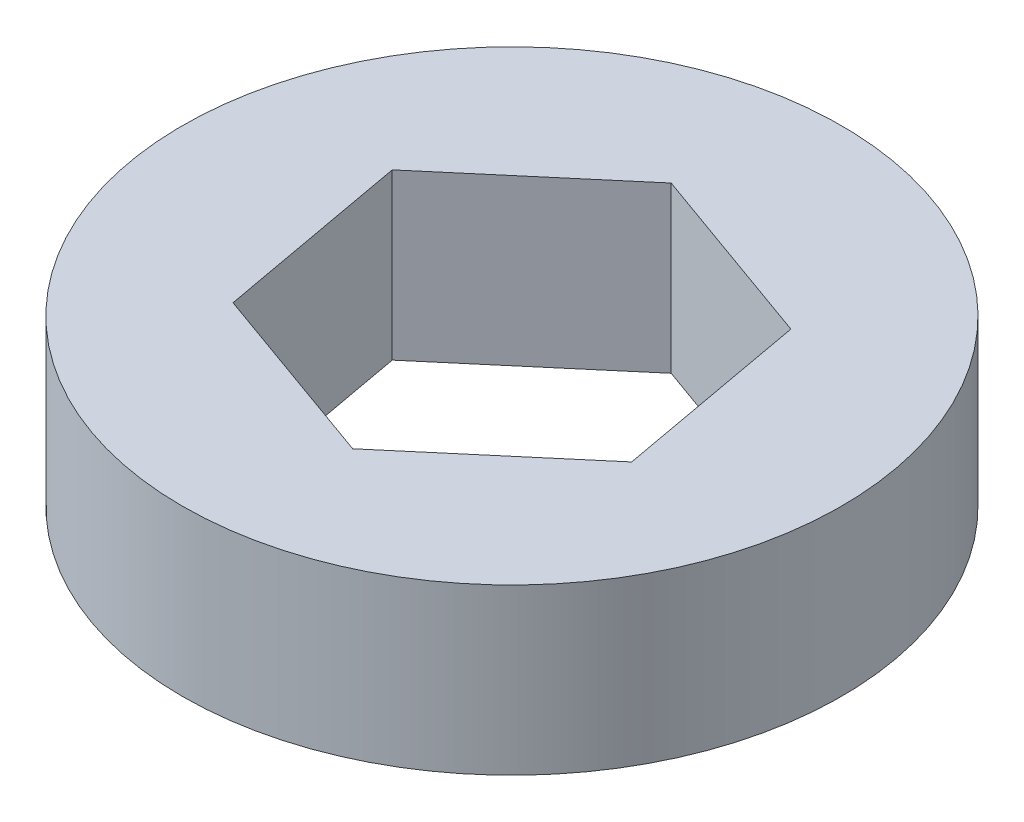
from build123d import *

# Parameters (mm, degrees)
SKETCH1_R           = 12.7
BOSS_EXTRUDE1_DEPTH = 6.35
CUT_EXTRUDE1_DEPTH  = 6.35


with BuildPart() as part:
    # Sketch1 → Boss-Extrude1 (new body)
    with BuildSketch(Plane(origin=(0, 0, 0), x_dir=(1, 0, 0), z_dir=(0, 1, 0))):
        Circle(SKETCH1_R)
    extrude(amount=BOSS_EXTRUDE1_DEPTH)

    # Sketch2 → Cut-Extrude1 (cut)
    with BuildSketch(Plane(origin=(0, 0, 0), x_dir=(1, 0, 0), z_dir=(0, 1, 0))):
        Polygon((-1.36635971, 7.502231833), (-7.180303208, 2.567813697), (-5.813943497, -4.934418136), (1.36635971, -7.502231833), (7.180303208, -2.567813697), (5.813943497, 4.934418136), align=None)
    extrude(amount=CUT_EXTRUDE1_DEPTH, mode=Mode.SUBTRACT)


solid = part.part
